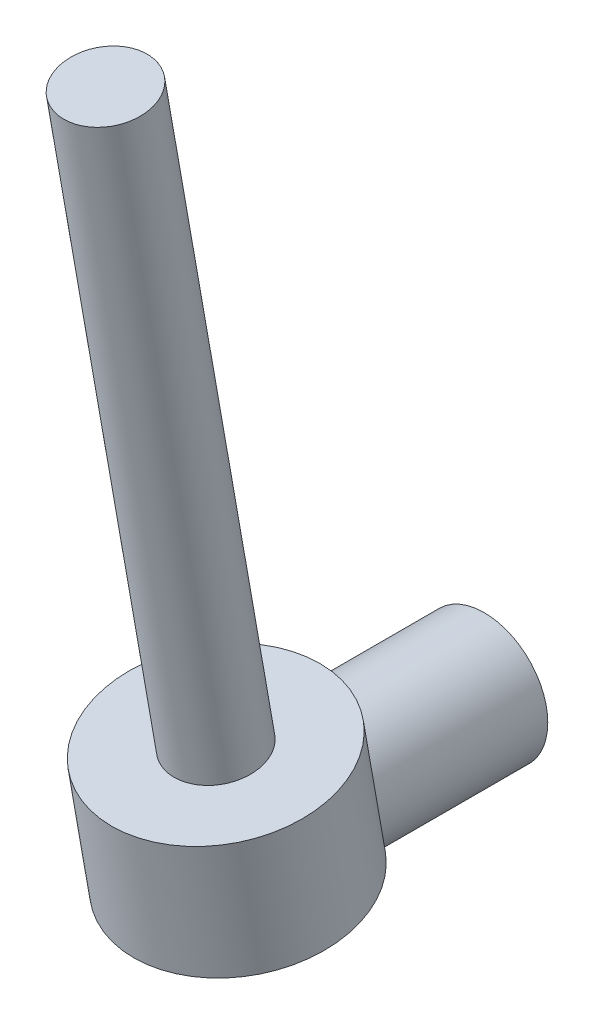
from build123d import *

# Parameters (mm, degrees)
SKETCH1_R                = 30
BOSS_EXTRUDE1_DEPTH      = 120
BOSS_EXTRUDE2_DEPTH      = 40
BOSS_EXTRUDE2_DEPTH_BACK = 20
SKETCH2_R                = 50
SKETCH3_R                = 20
BOSS_EXTRUDE3_DEPTH      = 300


with BuildPart() as part:
    # Sketch1 → Boss-Extrude1 (new body)
    with BuildSketch(Plane.XY):
        Circle(SKETCH1_R)
    extrude(amount=-BOSS_EXTRUDE1_DEPTH)

    # Sketch2 → Boss-Extrude2 (add, two sides: drawn at the far end of the back side and taken through both)
    with BuildSketch(Plane(origin=(0, 0, 0), x_dir=(1, 0, 0), z_dir=(0, 0.984807753012208, 0.17364817766693072)).offset(-BOSS_EXTRUDE2_DEPTH_BACK)):
        Circle(SKETCH2_R)
    extrude(amount=BOSS_EXTRUDE2_DEPTH + BOSS_EXTRUDE2_DEPTH_BACK)

    # Sketch3 → Boss-Extrude3 (add)
    with BuildSketch(Plane(origin=(0, 39.39231012, 6.945927107), x_dir=(1, 0, 0), z_dir=(0, 0.9848077530122081, 0.17364817766693072))):
        Circle(SKETCH3_R)
    extrude(amount=BOSS_EXTRUDE3_DEPTH)


solid = part.part
